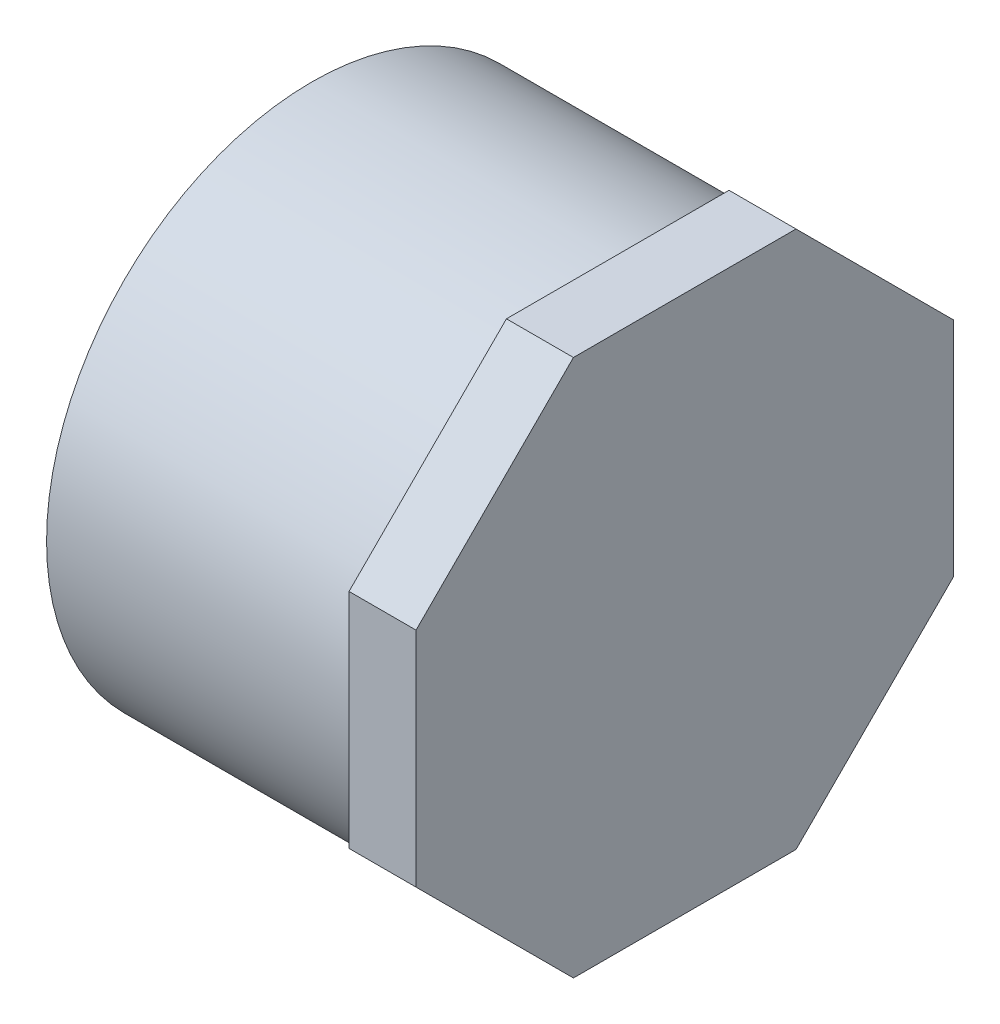
from build123d import *

# Parameters (mm, degrees)
SKETCH2_R           = 30.1625
BOSS_EXTRUDE1_DEPTH = 7.62


with BuildPart() as part:
    # Sketch1 → Revolve1 (revolve)
    with BuildSketch(Plane.XY):
        Polygon((-21.209, -30.1625), (21.209, -30.1625), (21.209, 0), (13.589, 0), (13.589, -26.2509), (-21.209, -26.2509), align=None)
    revolve(axis=Axis((-21.209, 0, 0), (1, 0, 0)))

    # Sketch2 → Boss-Extrude1 (add)
    with BuildSketch(Plane(origin=(21.209, 0, 0), x_dir=(0, 0, -1), z_dir=(1, 0, 0))):
        Polygon((-12.658107583, 30.559375), (-30.559375, 12.658107583), (-30.559375, -12.658107583), (-12.658107583, -30.559375), (12.658107583, -30.559375), (30.559375, -12.658107583), (30.559375, 12.658107583), (12.658107583, 30.559375), align=None)
        Circle(SKETCH2_R, mode=Mode.SUBTRACT)
    extrude(amount=-BOSS_EXTRUDE1_DEPTH)


solid = part.part
